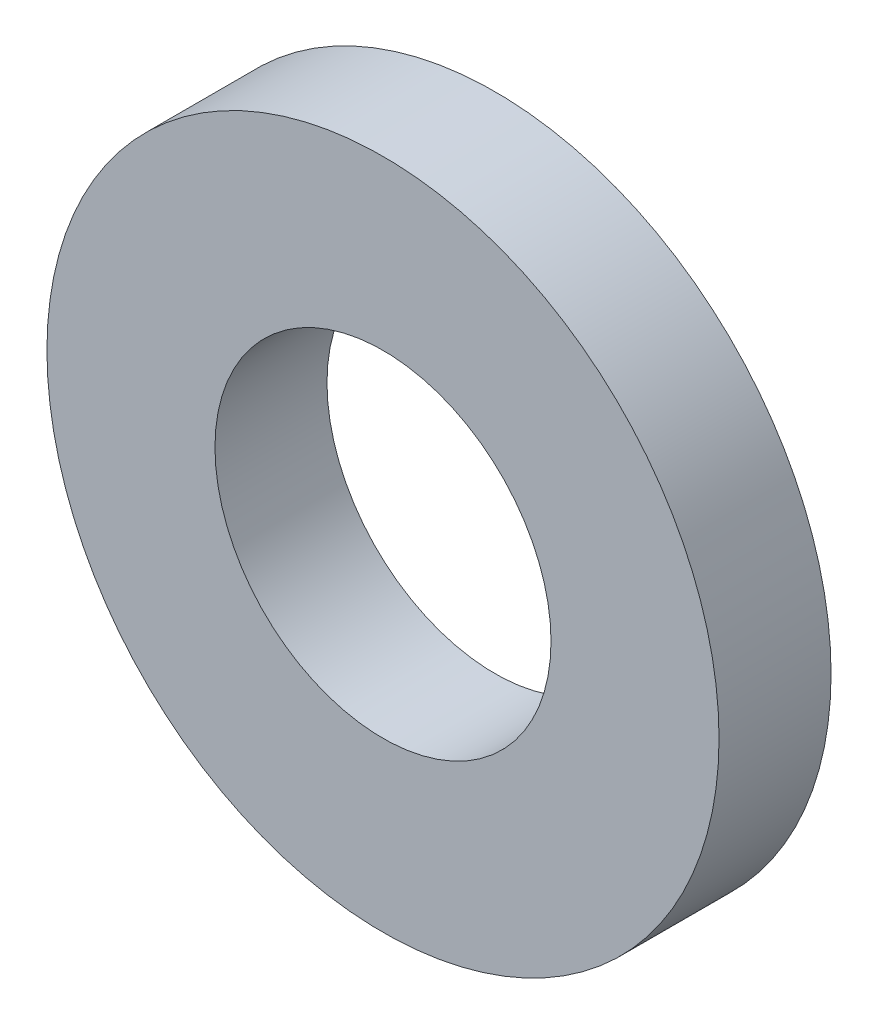
from build123d import *

# Parameters (mm, degrees)
ESQUISSE1_R        = 6
ESQUISSE1_R_2      = 3
BOSS_EXTRU_1_DEPTH = 2


with BuildPart() as part:
    # Esquisse1 → Boss.-Extru.1 (new body)
    with BuildSketch(Plane.XY):
        Circle(ESQUISSE1_R)
        Circle(ESQUISSE1_R_2, mode=Mode.SUBTRACT)
    extrude(amount=BOSS_EXTRU_1_DEPTH)


solid = part.part
